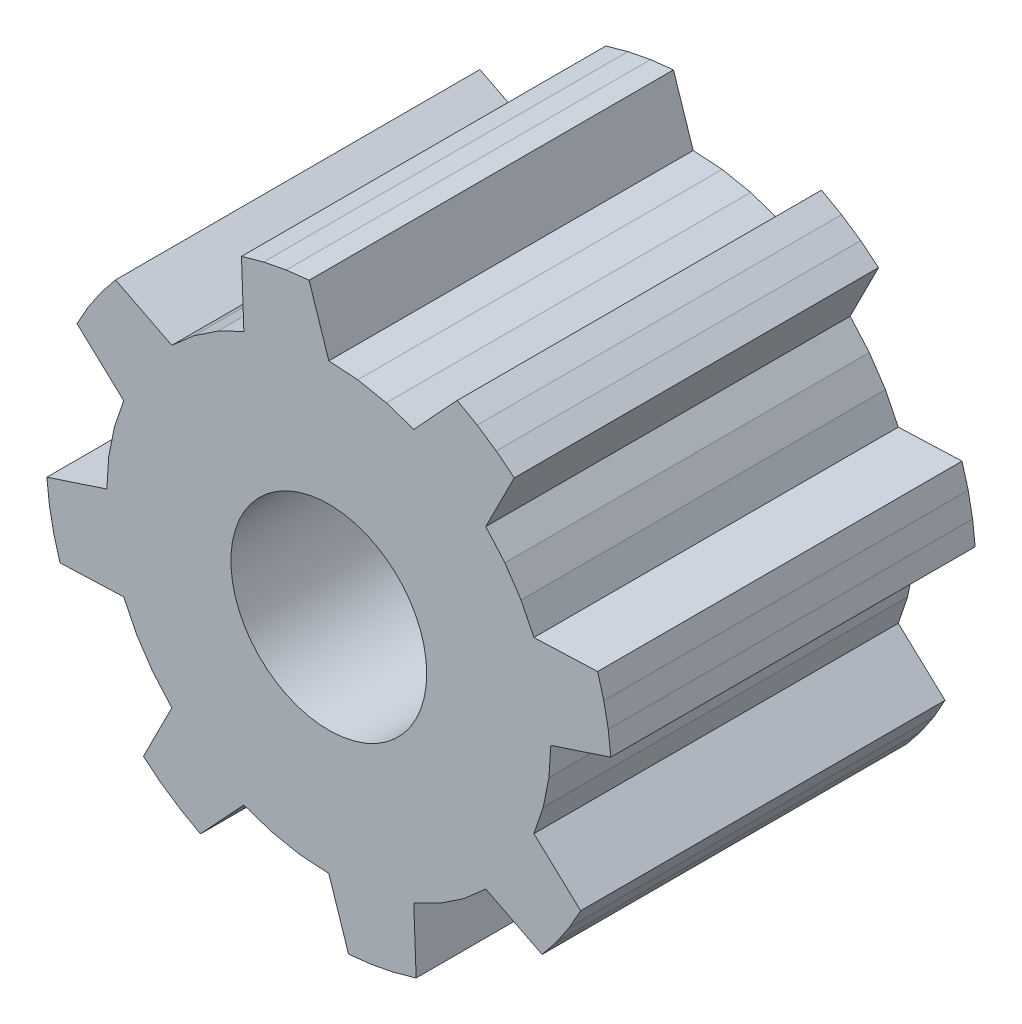
from build123d import *

# Parameters (mm, degrees)
SKETCH2_R           = 2.15
BOSS_EXTRUDE1_DEPTH = 8


with BuildPart() as part:
    # Sketch2 → Boss-Extrude1 (new body)
    with BuildSketch(Plane.XY):
        Polygon((4.873707771, 0), (4.832012177, -0.636146486), (4.707640171, -1.261407971), (4.502718925, -1.865087032), (5.52904892, -2.817190886), (5.281517029, -3.257688046), (4.998967171, -3.676585913), (4.683272839, -4.071106911), (3.44623208, -3.44623208), (2.966924906, -3.866571903), (2.436853886, -4.2207551), (1.865087032, -4.502718925), (1.917572975, -5.901682854), (1.431063056, -6.038129807), (0.935064673, -6.134541988), (0.432866603, -6.190280914), (0, -4.873707771), (-0.636146486, -4.832012177), (-1.261407971, -4.707640171), (-1.865087032, -4.502718925), (-2.817190886, -5.52904892), (-3.257688046, -5.281517029), (-3.676585913, -4.998967171), (-4.071106911, -4.683272839), (-3.44623208, -3.44623208), (-3.866571903, -2.966924906), (-4.2207551, -2.436853886), (-4.502718925, -1.865087032), (-5.901682854, -1.917572975), (-6.038129807, -1.431063056), (-6.134541988, -0.935064673), (-6.190280914, -0.432866603), (-4.873707771, 0), (-4.832012177, 0.636146486), (-4.707640171, 1.261407971), (-4.502718925, 1.865087032), (-5.52904892, 2.817190886), (-5.281517029, 3.257688046), (-4.998967171, 3.676585913), (-4.683272839, 4.071106911), (-3.44623208, 3.44623208), (-2.966924906, 3.866571903), (-2.436853886, 4.2207551), (-1.865087032, 4.502718925), (-1.917572975, 5.901682854), (-1.431063056, 6.038129807), (-0.935064673, 6.134541988), (-0.432866603, 6.190280914), (0, 4.873707771), (0.636146486, 4.832012177), (1.261407971, 4.707640171), (1.865087032, 4.502718925), (2.817190886, 5.52904892), (3.257688046, 5.281517029), (3.676585913, 4.998967171), (4.071106911, 4.683272839), (3.44623208, 3.44623208), (3.866571903, 2.966924906), (4.2207551, 2.436853886), (4.502718925, 1.865087032), (5.901682854, 1.917572975), (6.038129807, 1.431063056), (6.134541988, 0.935064673), (6.190280914, 0.432866603), align=None)
        Circle(SKETCH2_R, mode=Mode.SUBTRACT)
    extrude(amount=BOSS_EXTRUDE1_DEPTH)


solid = part.part
